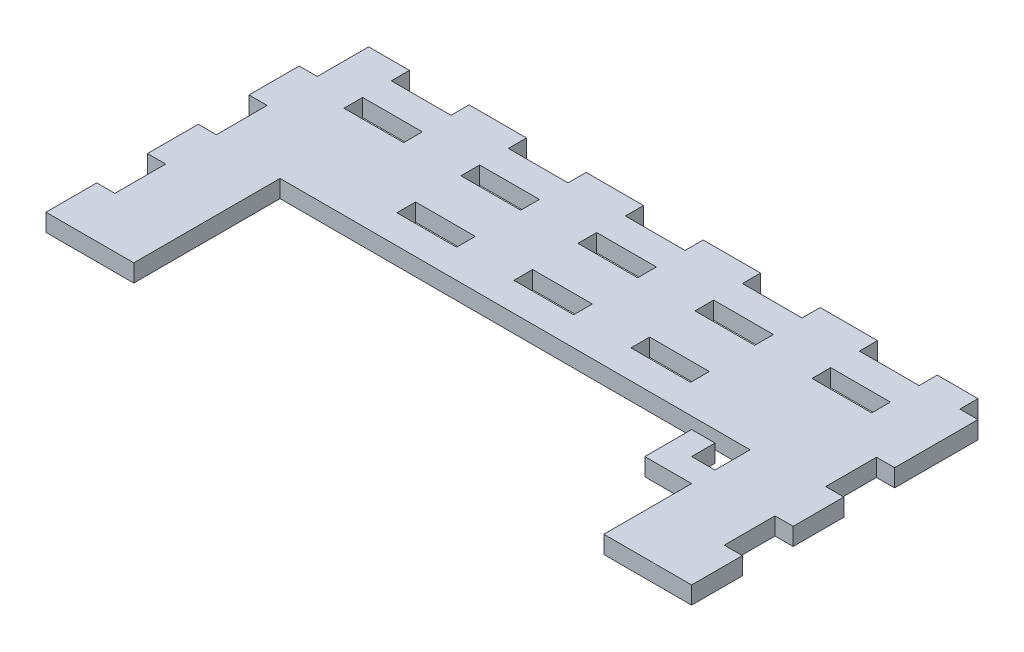
from build123d import *

# Parameters (mm, degrees)
BOSS_EXTRUDE1_DEPTH = 3
SKETCH3_W           = 3.2
SKETCH3_H           = 8.875
SKETCH3_H_2         = 8.675
SKETCH3_H_3         = 3.2
SKETCH3_W_2         = 10.2
CUT_EXTRUDE1_DEPTH  = 4
BOSS_EXTRUDE2_DEPTH = 3


with BuildPart() as part:
    # Sketch1 → Boss-Extrude1 (new body)
    with BuildSketch(Plane(origin=(0, 0, 0), x_dir=(1, 0, 0), z_dir=(0, 1, 0))):
        Polygon((15, 0), (15, 25), (95.344434203, 25), (95.344434203, 0), (110.344434203, 0), (110.344434203, 52.05), (0, 52.05), (0, 0), align=None)
    extrude(amount=-BOSS_EXTRUDE1_DEPTH)

    # Sketch3 → Cut-Extrude1 (cut, through all)
    with BuildSketch(Plane(origin=(0, 0, 0), x_dir=(1, 0, 0), z_dir=(0, 1, 0))):
        with Locations((1.5, 47.7125)):
            Rectangle(SKETCH3_W, SKETCH3_H)
        with Locations((1.5, 30.3625)):
            Rectangle(SKETCH3_W, SKETCH3_H_2)
        with Locations((1.5, 13.0125)):
            Rectangle(SKETCH3_W, SKETCH3_H_2)
        with Locations((108.844434203, 50.55)):
            Rectangle(SKETCH3_W, SKETCH3_H_3)
        with Locations((55.172217102, 50.55)):
            Rectangle(SKETCH3_W_2, SKETCH3_H_3)
        with Locations((55.172217102, 42.45)):
            Rectangle(SKETCH3_W_2, SKETCH3_H_3)
        with Locations((55.172217102, 31.5)):
            Rectangle(SKETCH3_W_2, SKETCH3_H_3)
        with Locations((35.172217102, 50.55)):
            Rectangle(SKETCH3_W_2, SKETCH3_H_3)
        with Locations((35.172217102, 42.45)):
            Rectangle(SKETCH3_W_2, SKETCH3_H_3)
        with Locations((35.172217102, 31.5)):
            Rectangle(SKETCH3_W_2, SKETCH3_H_3)
        with Locations((15.172217102, 50.55)):
            Rectangle(SKETCH3_W_2, SKETCH3_H_3)
        with Locations((15.172217102, 42.45)):
            Rectangle(SKETCH3_W_2, SKETCH3_H_3)
        with Locations((108.844434203, 13.0125)):
            Rectangle(SKETCH3_W, SKETCH3_H_2)
        with Locations((108.844434203, 30.3625)):
            Rectangle(SKETCH3_W, SKETCH3_H_2)
        with Locations((95.172217102, 50.55)):
            Rectangle(SKETCH3_W_2, SKETCH3_H_3)
        with Locations((95.172217102, 42.45)):
            Rectangle(SKETCH3_W_2, SKETCH3_H_3)
        with Locations((75.172217102, 31.5)):
            Rectangle(SKETCH3_W_2, SKETCH3_H_3)
        with Locations((75.172217102, 42.45)):
            Rectangle(SKETCH3_W_2, SKETCH3_H_3)
        with Locations((75.172217102, 50.55)):
            Rectangle(SKETCH3_W_2, SKETCH3_H_3)
    extrude(amount=-CUT_EXTRUDE1_DEPTH, mode=Mode.SUBTRACT)

    # Sketch4 → Boss-Extrude2 (add)
    with BuildSketch(Plane(origin=(0, 0, 0), x_dir=(1, 0, 0), z_dir=(0, 1, 0))):
        Polygon((95.344434203, 15), (87.344434203, 15), (87.344434203, 23), (91.344434203, 23), (91.344434203, 19), (95.344434203, 19), align=None)
    extrude(amount=-BOSS_EXTRUDE2_DEPTH)


solid = part.part
